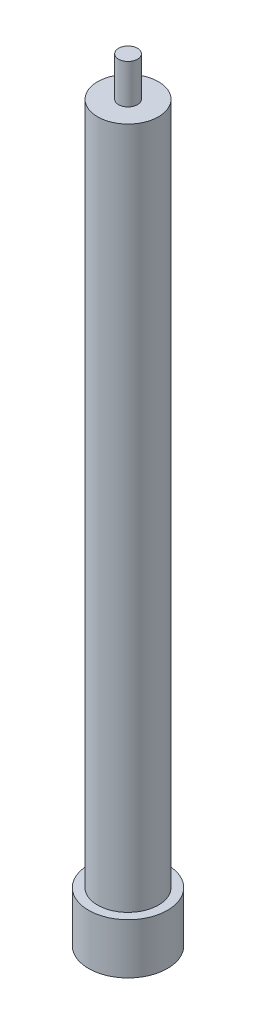
from build123d import *

# Parameters (mm, degrees)
SKETCH1_R           = 7.62
BOSS_EXTRUDE1_DEPTH = 622.3
SKETCH2_R           = 24.511
BOSS_EXTRUDE2_DEPTH = 590.55
SKETCH3_R           = 31.75
BOSS_EXTRUDE3_DEPTH = 40.64


with BuildPart() as part:
    # Sketch1 → Boss-Extrude1 (new body)
    with BuildSketch(Plane(origin=(0, 0, 0), x_dir=(1, 0, 0), z_dir=(0, 1, 0))):
        Circle(SKETCH1_R)
    extrude(amount=BOSS_EXTRUDE1_DEPTH)

    # Sketch2 → Boss-Extrude2 (add)
    with BuildSketch(Plane.XZ):
        Circle(SKETCH2_R)
    extrude(amount=-BOSS_EXTRUDE2_DEPTH)

    # Sketch3 → Boss-Extrude3 (add)
    with BuildSketch(Plane.XZ):
        Circle(SKETCH3_R)
    extrude(amount=-BOSS_EXTRUDE3_DEPTH)


solid = part.part
